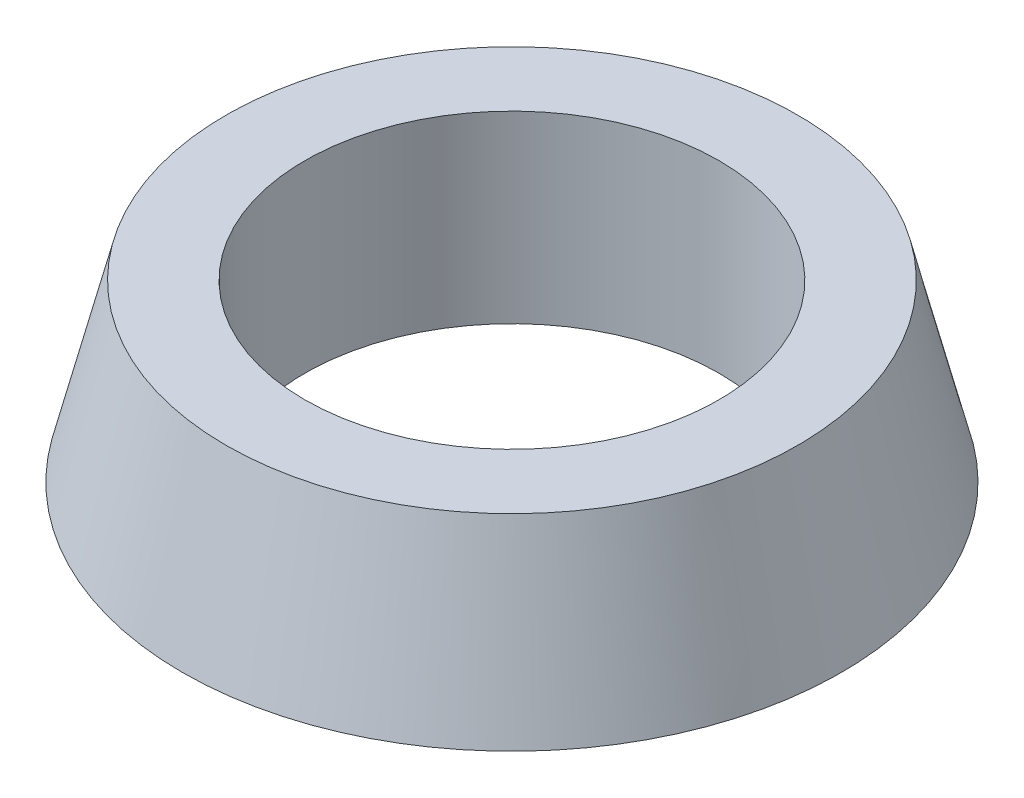
from build123d import *


with BuildPart() as part:
    # Sketch1 → Revolve1 (revolve)
    with BuildSketch(Plane.XY):
        Polygon((22.5, 0.06528296), (22.5, 20.06528296), (31.062767946, 20.06528296), (35.8, 1.06528296), (30.3, 1.06528296), (30.3, 0.06528296), align=None)
    revolve(axis=Axis((0, 0, 0), (0, -1, 0)))


solid = part.part
